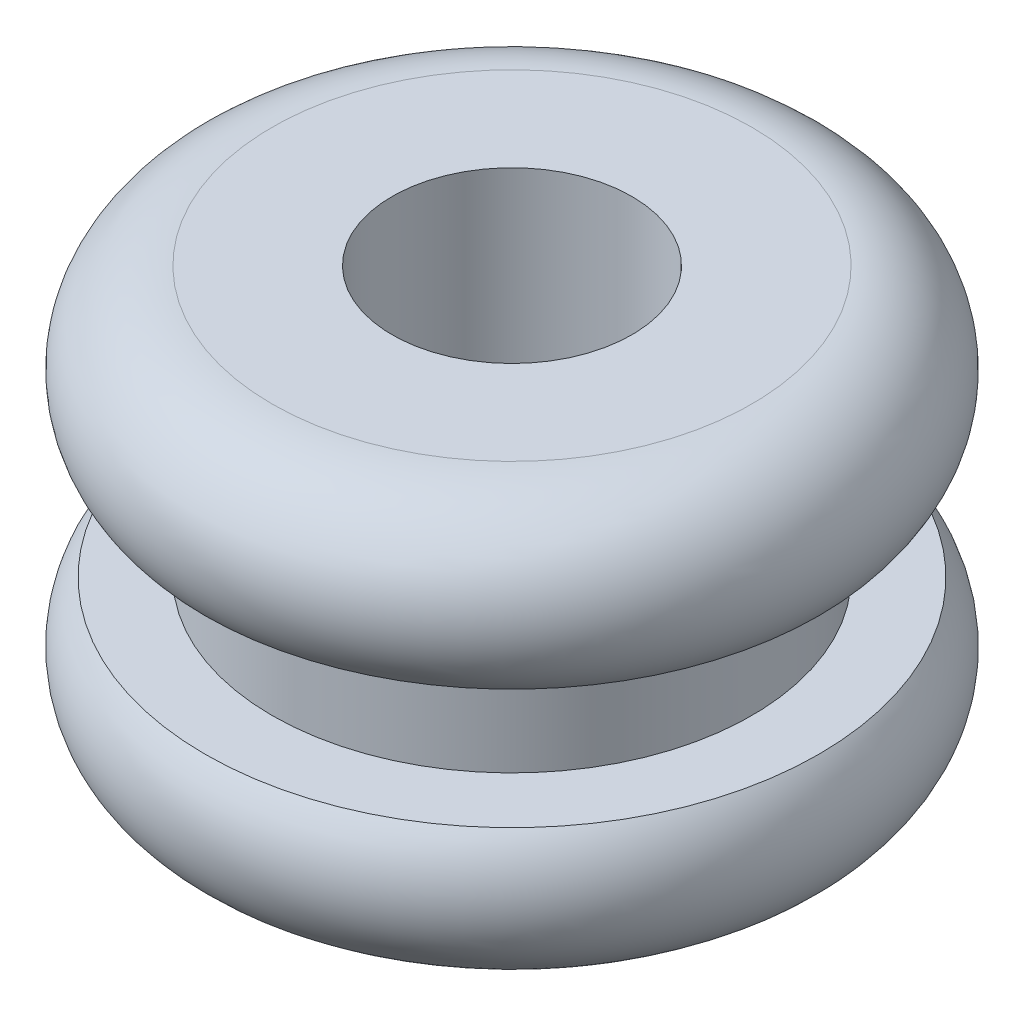
from build123d import *


with BuildPart() as part:
    # Sketch2 → Revolve1 (revolve)
    with BuildSketch(Plane(origin=(0, 0, 0), x_dir=(0, 0, -1), z_dir=(1, 0, 0))):
        with BuildLine():
            Line((-1.5875, -2.778125), (-1.5875, 2.778125))
            Line((-1.5875, 2.778125), (-3.175, 2.778125))
            ThreePointArc((-3.175, 2.778125), (-4.26188695, 2.073570621), (-4.062439479, 0.79375))
            Line((-4.062439479, 0.79375), (-3.175, 0.79375))
            Line((-3.175, 0.79375), (-3.175, -0.79375))
            Line((-3.175, -0.79375), (-4.062439479, -0.79375))
            ThreePointArc((-4.062439479, -0.79375), (-4.26188695, -2.073570621), (-3.175, -2.778125))
            Line((-3.175, -2.778125), (-1.5875, -2.778125))
        make_face()
    revolve(axis=Axis((0, -2.778125, 0), (0, 1, 0)))


solid = part.part
